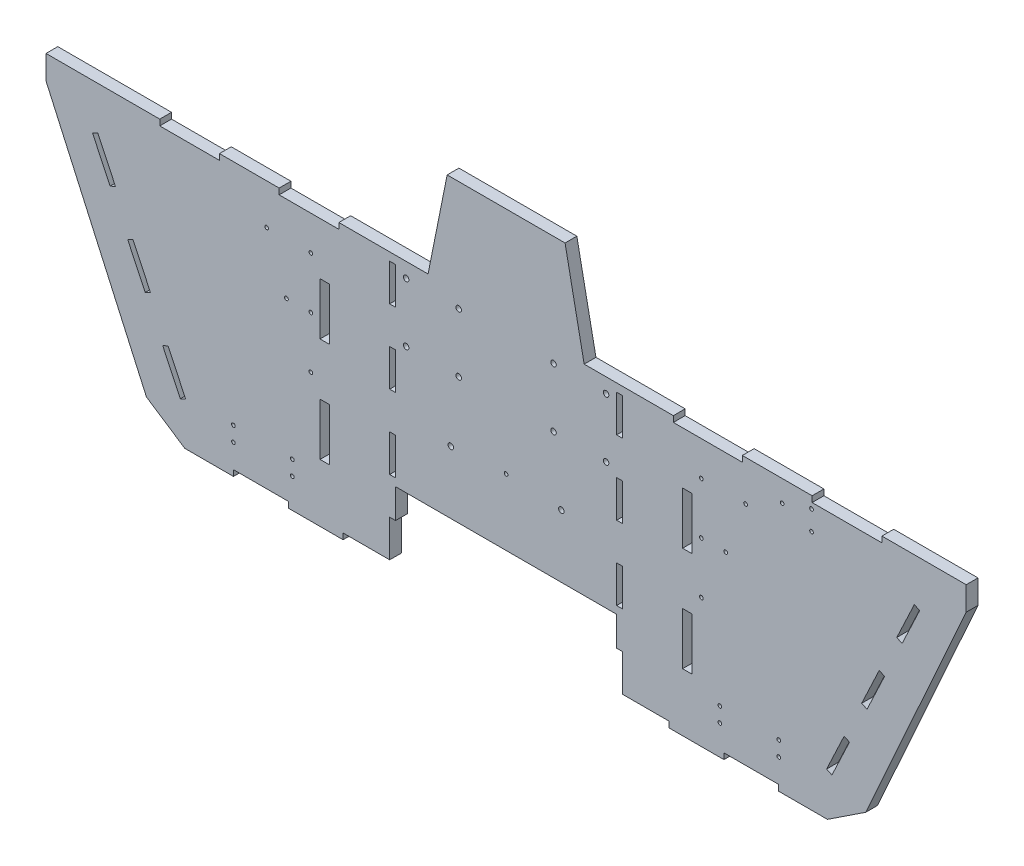
from build123d import *

# Parameters (mm, degrees)
BOSS_EXTRUDE1_DEPTH = 20.32
SKETCH2_W           = 120.284747719
SKETCH2_H           = 10.16
SKETCH2_W_2         = 118.872828106
SKETCH2_W_3         = 10.166490401
SKETCH2_H_2         = 89.916
SKETCH2_W_4         = 102.891608588
SKETCH2_W_5         = 94.453494603
SKETCH2_W_6         = 94.453494602
SKETCH2_W_7         = 3.175
SKETCH2_W_8         = 561.9496
CUT_EXTRUDE1_DEPTH  = 137.414
SKETCH3_W           = 337.058
SKETCH3_H           = 124.46
CUT_EXTRUDE2_DEPTH  = 137.414
SKETCH4_W           = 10.16
SKETCH4_H           = 63.685061479
SKETCH4_H_2         = 63.685061478
CUT_EXTRUDE3_DEPTH  = 20.32
SKETCH10_R          = 3.175
CUT_EXTRUDE5_DEPTH  = 20.32
SKETCH12_R          = 4.7625
CUT_EXTRUDE6_DEPTH  = 21.3200001
SKETCH14_R          = 3.175
CUT_EXTRUDE7_DEPTH  = 21.3200001
SKETCH15_R          = 4.7625
SKETCH15_R_2        = 3.175
CUT_EXTRUDE8_DEPTH  = 21.3200001
CUT_EXTRUDE9_DEPTH  = 21.3200001


with BuildPart() as part:
    # Sketch1 → Boss-Extrude1 (new body)
    with BuildSketch(Plane.XY):
        Polygon((94.041322477, 150.485716341), (-175.036761108, 150.485716341), (-142.097719316, 314.8709952), (61.102280684, 314.8709952), align=None)
        with BuildLine():
            Line((-606.997271248, -319.414283659), (526.001832617, -319.414283659))
            add(Edge.make_bspline(
                [(583.362059287, -282.457957765), (581.029219579, -287.649310181), (577.879080401, -292.734699958), (570.038270446, -301.965622016), (565.348976837, -306.100497209), (554.949172694, -312.800933616), (549.248266441, -315.360306939), (537.611112797, -318.678742027), (531.685117348, -319.440968422), (526.001832617, -319.414283659)],
                knots=[0, 0, 0, 0, 0.25, 0.25, 0.5, 0.5, 0.75, 0.75, 1, 1, 1, 1], degree=3))
            Line((583.362059287, -282.457957765), (777.91409763, 150.485716341))
            Line((777.91409763, 150.485716341), (-858.909536262, 150.485716341))
            Line((-858.909536262, 150.485716341), (-664.600308277, -281.91762311))
            add(Edge.make_bspline(
                [(-664.600308277, -281.91762311), (-662.275037436, -287.157802838), (-659.126015856, -292.295113907), (-651.27178065, -301.630322109), (-646.567903812, -305.817478055), (-636.124076479, -312.615880857), (-630.393770919, -315.220849348), (-618.687590773, -318.618481158), (-612.722057732, -319.414283659), (-606.997271248, -319.414283659)],
                knots=[0, 0, 0, 0, 0.25, 0.25, 0.5, 0.5, 0.75, 0.75, 1, 1, 1, 1], degree=3))
        make_face()
    extrude(amount=BOSS_EXTRUDE1_DEPTH)

    # Sketch2 → Cut-Extrude1 (cut)
    with BuildSketch(Plane(origin=(0, 0, 0), x_dir=(-1, 0, 0), z_dir=(0, 0, -1))):
        with Locations((-547.078117621, 145.405716341)):
            Rectangle(SKETCH2_W, SKETCH2_H)
        with Locations((-307.214581989, 145.405716341)):
            Rectangle(SKETCH2_W_2, SKETCH2_H)
        with Locations((-271.919035422, 5.451716341)):
            Rectangle(SKETCH2_W_3, SKETCH2_H_2)
        with Locations((-271.919035422, -174.380283659)):
            Rectangle(SKETCH2_W_3, SKETCH2_H_2)
        with Locations((352.914474055, -174.380283659)):
            Rectangle(SKETCH2_W_3, SKETCH2_H_2)
        with Locations((352.914474055, 5.451716341)):
            Rectangle(SKETCH2_W_3, SKETCH2_H_2)
        with Locations((380.219410862, 145.405716341)):
            Rectangle(SKETCH2_W_4, SKETCH2_H)
        with Locations((586.002628038, 145.405716341)):
            Rectangle(SKETCH2_W_4, SKETCH2_H)
        with Locations((-382.157322588, -314.334283659)):
            Rectangle(SKETCH2_W_5, SKETCH2_H)
        with Locations((463.152761219, -314.334283659)):
            Rectangle(SKETCH2_W_6, SKETCH2_H)
        with Locations((-278.589780623, -174.380283659)):
            Rectangle(SKETCH2_W_7, SKETCH2_H_2)
        with Locations((-265.248290222, -174.380283659)):
            Rectangle(SKETCH2_W_7, SKETCH2_H_2)
        with Locations((-278.589780623, 5.451716341)):
            Rectangle(SKETCH2_W_7, SKETCH2_H_2)
        with Locations((-265.248290222, 5.451716341)):
            Rectangle(SKETCH2_W_7, SKETCH2_H_2)
        with Locations((346.243728854, 5.451716341)):
            Rectangle(SKETCH2_W_7, SKETCH2_H_2)
        with Locations((359.585219255, 5.451716341)):
            Rectangle(SKETCH2_W_7, SKETCH2_H_2)
        with Locations((346.243728854, -174.380283659)):
            Rectangle(SKETCH2_W_7, SKETCH2_H_2)
        with Locations((359.585219255, -174.380283659)):
            Rectangle(SKETCH2_W_7, SKETCH2_H_2)
        with Locations((40.497719316, -314.334283659)):
            Rectangle(SKETCH2_W_8, SKETCH2_H)
    extrude(amount=-CUT_EXTRUDE1_DEPTH, mode=Mode.SUBTRACT)

    # Sketch3 → Cut-Extrude2 (cut)
    with BuildSketch(Plane.XY.offset(20.32)):
        with Locations((-40.497719316, -257.184283659)):
            Rectangle(SKETCH3_W, SKETCH3_H)
    extrude(amount=-CUT_EXTRUDE2_DEPTH, mode=Mode.SUBTRACT)

    # Sketch4 → Cut-Extrude3 (cut)
    with BuildSketch(Plane(origin=(0, 0, 0), x_dir=(-1, 0, 0), z_dir=(0, 0, -1))):
        Polygon((-160.162280684, -245.551796758), (-160.162280684, -309.254283659), (-128.031280684, -309.254283659), (-128.031280684, -194.954283659), (-150.002280684, -194.954283659), (-150.002280684, -245.551796758), align=None)
        Polygon((241.157719316, -309.254283659), (241.157719316, -245.551796758), (230.997719316, -245.551796758), (230.997719316, -194.954283659), (209.026719316, -194.954283659), (209.026719316, -309.254283659), align=None)
        with Locations((-155.082280684, -150.02420454)):
            Rectangle(SKETCH4_W, SKETCH4_H)
        with Locations((-155.082280684, -22.654081584)):
            Rectangle(SKETCH4_W, SKETCH4_H)
        with Locations((-155.082280684, 104.698615951)):
            Rectangle(SKETCH4_W, SKETCH4_H_2)
        with Locations((236.077719316, -150.02420454)):
            Rectangle(SKETCH4_W, SKETCH4_H)
        with Locations((236.077719316, -22.654081584)):
            Rectangle(SKETCH4_W, SKETCH4_H)
        with Locations((236.077719316, 104.698615951)):
            Rectangle(SKETCH4_W, SKETCH4_H_2)
    extrude(amount=-CUT_EXTRUDE3_DEPTH, mode=Mode.SUBTRACT)

    # Sketch10 → Cut-Extrude5 (cut)
    with BuildSketch(Plane.XY):
        with Locations((372.252552874, 80.840970313)):
            Circle(SKETCH10_R)
        with Locations((296.052552874, 80.840970313)):
            Circle(SKETCH10_R)
        with Locations((296.052552874, -8.059029687)):
            Circle(SKETCH10_R)
        with Locations((338.076100273, -8.059019539)):
            Circle(SKETCH10_R)
        with Locations((296.052552874, -96.959029687)):
            Circle(SKETCH10_R)
        with Locations((327.929280684, -242.858683659)):
            Circle(SKETCH10_R)
        with Locations((327.929280684, -268.258683659)):
            Circle(SKETCH10_R)
        with Locations((429.529280684, -268.258683659)):
            Circle(SKETCH10_R)
        with Locations((429.529280684, -242.858683659)):
            Circle(SKETCH10_R)
        with Locations((-510.524719316, -242.858683659)):
            Circle(SKETCH10_R)
        with Locations((-510.524719316, -268.258683659)):
            Circle(SKETCH10_R)
        with Locations((-408.924719316, -268.258683659)):
            Circle(SKETCH10_R)
        with Locations((-408.924719316, -242.858683659)):
            Circle(SKETCH10_R)
        with Locations((-377.047991505, -96.959029687)):
            Circle(SKETCH10_R)
        with Locations((-419.071538905, -8.059019539)):
            Circle(SKETCH10_R)
        with Locations((-377.047991505, -8.059029687)):
            Circle(SKETCH10_R)
        with Locations((-377.047991505, 80.840970313)):
            Circle(SKETCH10_R)
        with Locations((-453.247991505, 80.840970313)):
            Circle(SKETCH10_R)
    extrude(amount=CUT_EXTRUDE5_DEPTH, mode=Mode.SUBTRACT)

    # Sketch12 → Cut-Extrude6 (cut, through all)
    with BuildSketch(Plane(origin=(0, 0, 0), x_dir=(-1, 0, 0), z_dir=(0, 0, -1))):
        with Locations((-41.226780684, 125.085716341)):
            Circle(SKETCH12_R)
        with Locations((-41.226780684, 23.485716341)):
            Circle(SKETCH12_R)
        with Locations((-131.777780684, 23.485716341)):
            Circle(SKETCH12_R)
        with Locations((-131.777780684, 125.085716341)):
            Circle(SKETCH12_R)
        with Locations((212.773219316, 23.485716341)):
            Circle(SKETCH12_R)
        with Locations((212.773219316, 125.085716341)):
            Circle(SKETCH12_R)
        with Locations((122.222219316, 125.085716341)):
            Circle(SKETCH12_R)
        with Locations((122.222219316, 23.485716341)):
            Circle(SKETCH12_R)
    extrude(amount=-CUT_EXTRUDE6_DEPTH, mode=Mode.SUBTRACT)

    # Sketch14 → Cut-Extrude7 (cut, through all)
    with BuildSketch(Plane.XY.offset(20.32)):
        with Locations((435.255534848, 113.379343598)):
            Circle(SKETCH14_R)
        with Locations((485.903167936, 96.510716341)):
            Circle(SKETCH14_R)
        with Locations((485.903167936, 130.247970855)):
            Circle(SKETCH14_R)
    extrude(amount=-CUT_EXTRUDE7_DEPTH, mode=Mode.SUBTRACT)

    # Sketch15 → Cut-Extrude8 (cut, through all)
    with BuildSketch(Plane(origin=(0, 0, 0), x_dir=(-1, 0, 0), z_dir=(0, 0, -1))):
        with Locations((-54.752280684, -87.004283659)):
            Circle(SKETCH15_R)
        with Locations((135.747719316, -87.004283659)):
            Circle(SKETCH15_R)
        with Locations((40.497719316, -80.654283659)):
            Circle(SKETCH15_R_2)
    extrude(amount=-CUT_EXTRUDE8_DEPTH, mode=Mode.SUBTRACT)

    # Sketch16 → Cut-Extrude9 (cut, through all)
    with BuildSketch(Plane(origin=(0, 0, 0), x_dir=(-1, 0, 0), z_dir=(0, 0, -1))):
        Polygon((602.079238464, -249.356226254), (592.887014254, -245.028569373), (623.124185153, -180.802855087), (632.316409363, -185.130511968), align=None)
        Polygon((662.553580262, -120.904797683), (653.361356052, -116.577140802), (683.598526952, -52.351426516), (692.790751161, -56.679083397), align=None)
        Polygon((723.027922061, 7.546630889), (713.835697851, 11.87428777), (744.07286875, 76.100002056), (753.26509296, 71.772345174), align=None)
        Polygon((594.297271248, -319.414283659), (660.407848466, -275.75518023), (833.509536262, 109.454254463), (833.509536262, 150.485716341), (853.117470666, 153.088498724), (880.087987184, 153.088498724), (670.30731137, -269.21762311), (671.822506806, -327.097732355), (581.920341153, -337.589747111), align=None)
        Polygon((-752.51409763, 150.485716341), (-772.122032035, 153.088498724), (-799.092548552, 153.088498724), (-589.311872738, -269.21762311), (-590.827068174, -327.097732355), (-500.924902522, -337.589747111), (-513.301832617, -319.414283659), (-579.412409834, -275.75518023), (-752.51409763, 109.454254463), align=None)
        Polygon((-672.269654328, 71.772345174), (-663.077430118, 76.100002056), (-632.840259219, 11.87428777), (-642.032483429, 7.546630889), align=None)
        Polygon((-581.55814163, -120.904797683), (-611.795312529, -56.679083397), (-602.60308832, -52.351426516), (-572.365917421, -116.577140802), align=None)
        Polygon((-551.320970731, -185.130511968), (-542.128746521, -180.802855087), (-511.891575622, -245.028569373), (-521.083799832, -249.356226254), align=None)
    extrude(amount=-CUT_EXTRUDE9_DEPTH, mode=Mode.SUBTRACT)


solid = part.part
